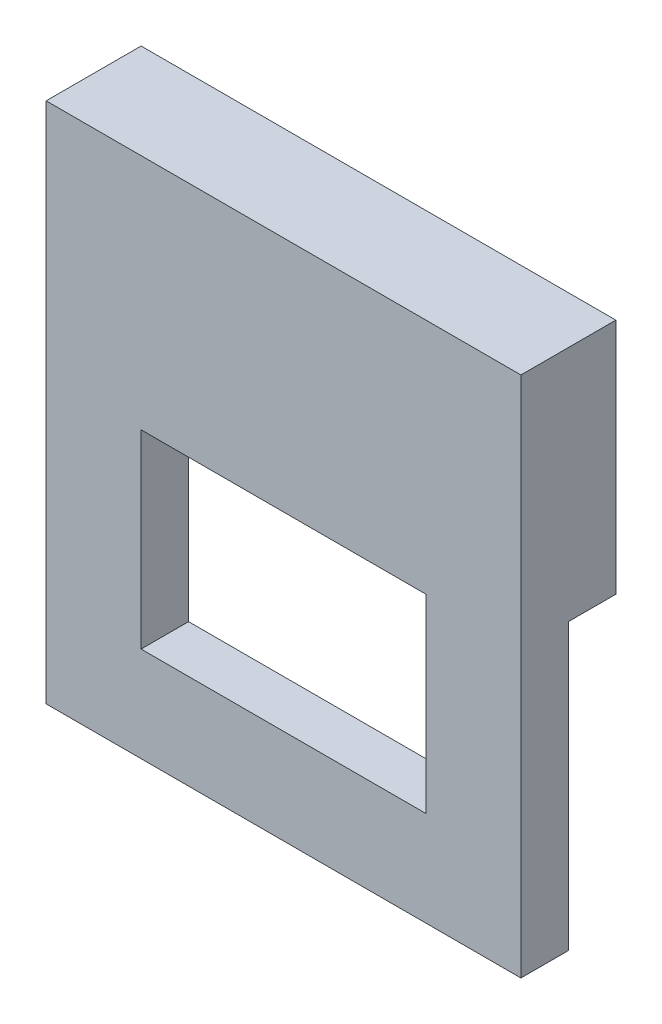
from build123d import *

# Parameters (mm, degrees)
LINEAR_AUSTRAGEN1_DEPTH = 5
SKIZZE2_W               = 6
SKIZZE2_H               = 4
LINEAR_AUSTRAGEN2_DEPTH = 10


with BuildPart() as part:
    # Skizze1 → Linear austragen1 (new body, symmetric)
    with BuildSketch(Plane(origin=(0, 0, 0), x_dir=(0, 0, -1), z_dir=(1, 0, 0))):
        Polygon((0, 0), (1, 0), (1, 5), (-1, 5), (-1, -6), (0, -6), align=None)
    extrude(amount=LINEAR_AUSTRAGEN1_DEPTH, both=True)

    # Skizze2 → Linear austragen2 (cut)
    with BuildSketch(Plane.XY.offset(1)):
        with Locations((0, -2)):
            Rectangle(SKIZZE2_W, SKIZZE2_H)
    extrude(amount=-LINEAR_AUSTRAGEN2_DEPTH, mode=Mode.SUBTRACT)


solid = part.part
